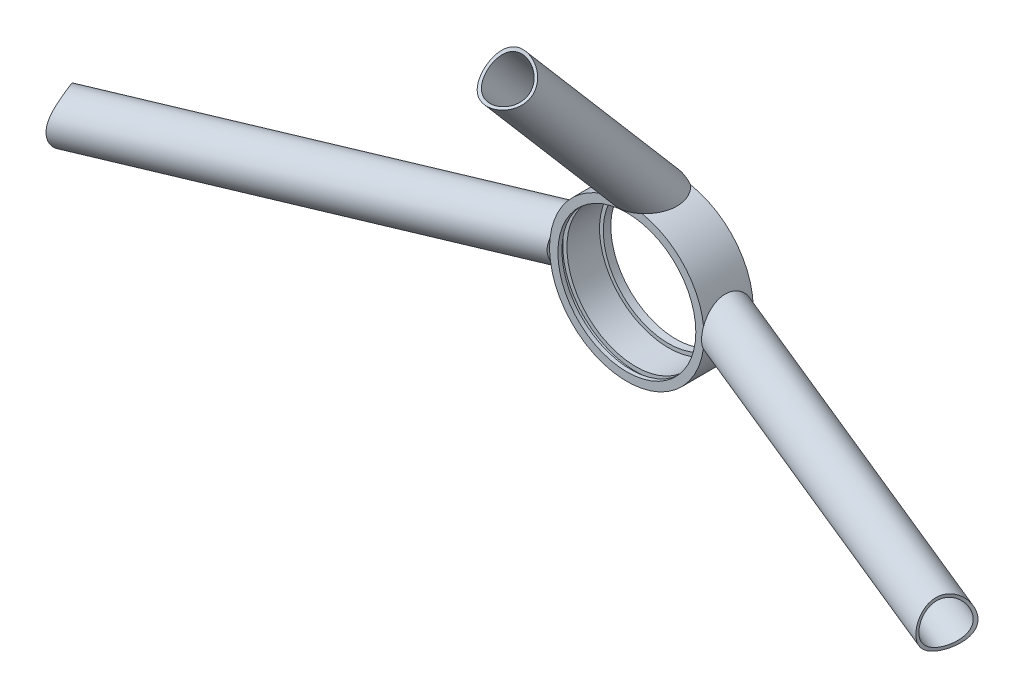
from build123d import *

# Parameters (mm, degrees)
SKETCH1_R                           = 30.8
SKETCH1_R_2                         = 27.5
EXTRUDE1_DEPTH                      = 19.6
SKETCH2_R                           = 30.8
SKETCH2_R_2                         = 26
EXTRUDE2_DEPTH                      = 3
SKETCH3_W                           = 2
SKETCH3_H                           = 29.2
LEFT_TUBE_REACH                     = 239.929
LEFT_TUBE_END_RADIUS                = 30.8
SKETCH6_R                           = 9.525
SKETCH6_R_2                         = 8.325
TOP_TUBE_REACH                      = 256.58
TOP_TUBE_END_RADIUS                 = 30.8
SKETCH9_R                           = 9.525
SKETCH9_R_2                         = 8.325
SKETCH10_W                          = 105.113288116
SKETCH10_H                          = 41.004966603
CUT_REAR_END_OF_TOP_TUBE_DEPTH      = 245.195163669
CUT_REAR_END_OF_TOP_TUBE_DEPTH_BACK = 245.195163669
SKETCH11_R                          = 19.2
EXTRUDE8_DEPTH                      = 245.195163669
EXTRUDE8_DEPTH_BACK                 = 245.195163669
EXTRUDETRIMLTUBELEND_DEPTH          = 238.522883474
EXTRUDETRIMLTUBELEND_DEPTH_BACK     = 238.522883474


with BuildPart() as part:
    # Sketch1 → Extrude1 (new body)
    with BuildSketch(Plane.XY):
        Circle(SKETCH1_R)
        Circle(SKETCH1_R_2, mode=Mode.SUBTRACT)
    extrude(amount=EXTRUDE1_DEPTH)

    # Sketch2 → Extrude2 (add)
    with BuildSketch(Plane.XY):
        Circle(SKETCH2_R)
        Circle(SKETCH2_R_2, mode=Mode.SUBTRACT)
    extrude(amount=EXTRUDE2_DEPTH)

    # Sketch3 → Cut-Revolve1 (revolve, cut)
    with BuildSketch(Plane(origin=(0, 0, 0), x_dir=(0, 0, -1), z_dir=(1, 0, 0)), mode=Mode.PRIVATE) as cut_revolve1_sk:
        with Locations((-17, 14.6)):
            Rectangle(SKETCH3_W, SKETCH3_H)
    revolve(cut_revolve1_sk.sketch.rotate(Axis((0, 0, 24.485384535), (0, 0, -1)), 90), axis=Axis((0, 0, 24.485384535), (0, 0, -1)), mode=Mode.SUBTRACT)


with BuildPart() as body_2:
    # Left Tube: up to this cylinder (the profile starts outside it)
    left_tube_end = Plane(origin=(0, 0, 83.745189), z_dir=(0, 0, -1)) * Cylinder(LEFT_TUBE_END_RADIUS, 542.458, mode=Mode.PRIVATE)
    # Sketch6 → Left Tube (new, up to the surface)
    with BuildSketch(Plane(origin=(192.46, -2.624442152, 75.154190192), x_dir=(0.3719880854240879, -0.007773528224829268, -0.9282049539630024), z_dir=(0.9281170717911996, -0.01299268005091301, 0.3720616767618291)), mode=Mode.PRIVATE) as left_tube_sk1:
        with Locations(Location((0, 0, 0), (0, 0, 0.445432444))):
            Circle(SKETCH6_R)
        with Locations(Location((0, 0, 0), (0, 0, 0.445432444))):
            Circle(SKETCH6_R_2, mode=Mode.SUBTRACT)
    left_tube_tool1 = extrude(left_tube_sk1.sketch, amount=-LEFT_TUBE_REACH, mode=Mode.PRIVATE) - left_tube_end
    add(left_tube_tool1.solids().sort_by_distance((189.016058, -2.624442, 83.745189))[0])


with BuildPart() as body_3:
    # MirrorRightTube: mirrored copy
    add(body_2.part.mirror(Plane(origin=(0, 0, 0), x_dir=(0, 0, 1), z_dir=(1, 0, 0))))


with BuildPart() as body_4:
    # Top Tube: up to this cylinder (the profile starts outside it)
    top_tube_end = Plane(origin=(0, 0, 72.092004), z_dir=(0, 0, -1)) * Cylinder(TOP_TUBE_END_RADIUS, 575.76, mode=Mode.PRIVATE)
    # Sketch9 → Top Tube (new, up to the surface)
    with BuildSketch(Plane(origin=(0, 111.087059338, 79.125083324), x_dir=(1, 0, 0), z_dir=(0, 0.7598734904595021, 0.650070979583686)), mode=Mode.PRIVATE) as top_tube_sk1:
        with Locations(Location((0, 0, 0), (0, 0, 270))):
            Circle(SKETCH9_R)
        with Locations(Location((0, 0, 0), (0, 0, 270))):
            Circle(SKETCH9_R_2, mode=Mode.SUBTRACT)
    top_tube_tool1 = extrude(top_tube_sk1.sketch, amount=-TOP_TUBE_REACH, mode=Mode.PRIVATE) - top_tube_end
    add(top_tube_tool1.solids().sort_by_distance((0, 117.103851, 72.092004))[0])

    # Sketch10 → Cut Rear End of Top Tube (cut, two sides)
    with BuildSketch(Plane(origin=(0, 0, 0), x_dir=(1, 0, 0), z_dir=(0, 1, 0))) as cut_rear_end_of_top_tube_sk:
        with Locations((-1.580650949, 20.502483301)):
            Rectangle(SKETCH10_W, SKETCH10_H)
    extrude(amount=CUT_REAR_END_OF_TOP_TUBE_DEPTH, mode=Mode.SUBTRACT)
    extrude(cut_rear_end_of_top_tube_sk.sketch, amount=-CUT_REAR_END_OF_TOP_TUBE_DEPTH_BACK, mode=Mode.SUBTRACT)

    # Sketch11 → Extrude8 (cut, two sides)
    with BuildSketch(Plane(origin=(0, 0, 0), x_dir=(0, 0, -1), z_dir=(1, 0, 0))) as extrude8_sk:
        with Locations((-79.125083324, 111.087059338)):
            Circle(SKETCH11_R)
    extrude(amount=EXTRUDE8_DEPTH, mode=Mode.SUBTRACT)
    extrude(extrude8_sk.sketch, amount=-EXTRUDE8_DEPTH_BACK, mode=Mode.SUBTRACT)


with BuildPart() as extrudetrimltubelend_tool:
    # Sketch18 → ExtrudeTrimLTubeLEnd (new, two sides)
    with BuildSketch(Plane(origin=(0, 0, 0), x_dir=(-1, 0, 0), z_dir=(0, -1, 0))) as extrudetrimltubelend_sk:
        with BuildLine():
            Line((-199.604187223, -57.332838141), (-197.139596936, -63.480819683))
            Line((-197.139596936, -63.480819683), (-241.510746217, -81.268235412))
            Line((-241.510746217, -81.268235412), (-215.23664349, -146.809635697))
            Line((-215.23664349, -146.809635697), (-170.865494208, -129.022219967))
            Line((-170.865494208, -129.022219967), (-185.315812777, -92.975542243))
            ThreePointArc((-185.315812777, -92.975542243), (-174.638647949, -68.010002968), (-199.604187223, -57.332838141))
        make_face()
        with BuildLine():
            Line((170.865494208, -129.022219967), (185.315812777, -92.975542243))
            ThreePointArc((185.315812777, -92.975542243), (174.638647949, -68.010002968), (199.604187223, -57.332838141))
            Line((199.604187223, -57.332838141), (197.139596936, -63.480819683))
            Line((197.139596936, -63.480819683), (241.510746217, -81.268235412))
            Line((241.510746217, -81.268235412), (215.23664349, -146.809635697))
            Line((215.23664349, -146.809635697), (170.865494208, -129.022219967))
        make_face()
    extrude(amount=EXTRUDETRIMLTUBELEND_DEPTH)
    extrude(extrudetrimltubelend_sk.sketch, amount=-EXTRUDETRIMLTUBELEND_DEPTH_BACK)


with BuildPart() as body_2_1:
    add(body_2.part)

    # ExtrudeTrimLTubeLEnd: cut by extrudetrimltubelend_tool
    add(extrudetrimltubelend_tool.part, mode=Mode.SUBTRACT)


with BuildPart() as body_3_1:
    add(body_3.part)

    # ExtrudeTrimLTubeLEnd: cut by extrudetrimltubelend_tool
    add(extrudetrimltubelend_tool.part, mode=Mode.SUBTRACT)


with BuildPart() as part_1:
    add(part.part)

    # Combine1: union body 2, body 3, body 4
    add(body_2_1.part)
    add(body_3_1.part)
    add(body_4.part)


solid = part_1.part
